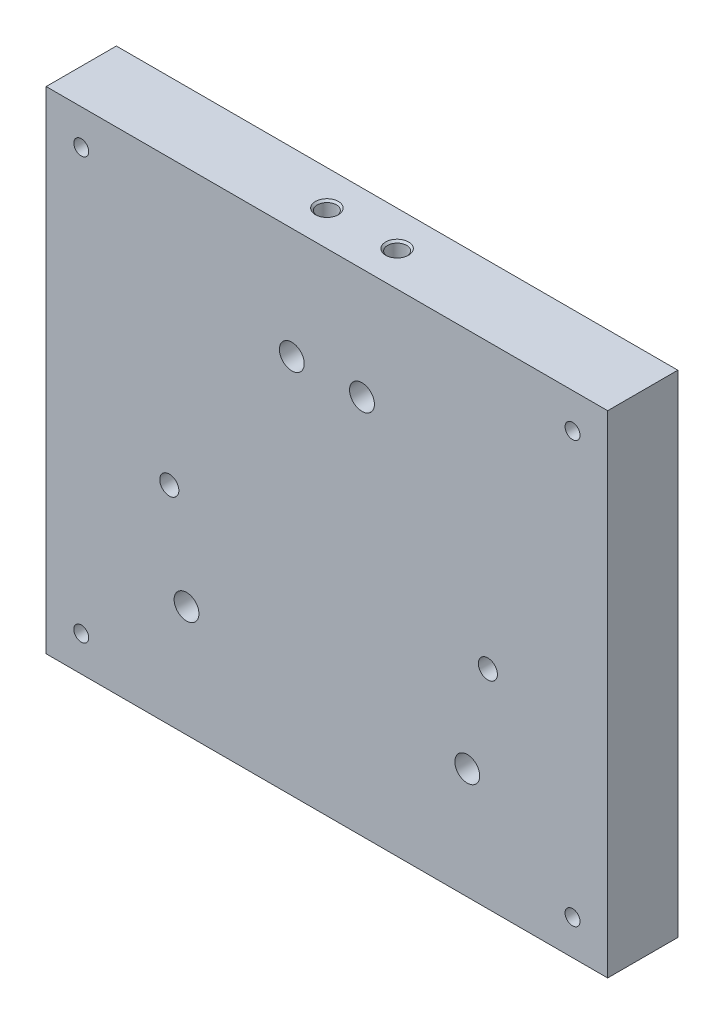
from build123d import *

# Parameters (mm, degrees)
SKETCH1_W                       = 101.6
SKETCH1_H                       = 88.9
BOSS_EXTRUDE1_DEPTH             = 12.7
F_8_32_TAPPED_HOLE1_D           = 3.4544
F_8_32_TAPPED_HOLE1_DEPTH       = 19.05
F_8_32_TAPPED_HOLE1_CSINK_D     = 4.1656
F_8_32_TAPPED_HOLE1_CSINK_ANGLE = 90
F_8_32_TAPPED_HOLE1_TIP         = 1.037806461
F_8_CLEARANCE_HOLE2_D           = 4.4958
F_8_CLEARANCE_HOLE2_DEPTH       = 25.4
F_8_CLEARANCE_HOLE2_TIP         = 1.350674586
F_6_32_TAPPED_HOLE1_D           = 2.7051
F_8_32_TAPPED_HOLE2_D           = 3.4544
F_8_32_TAPPED_HOLE3_D           = 3.4544
F_8_32_TAPPED_HOLE3_DEPTH       = 19.05
F_8_32_TAPPED_HOLE3_TIP         = 1.037806461
F_8_CLEARANCE_HOLE3_D           = 4.4958
F_8_CLEARANCE_HOLE3_DEPTH       = 19.05
F_8_CLEARANCE_HOLE3_TIP         = 1.350674586


with BuildPart() as part:
    # Sketch1 → Boss-Extrude1 (new body)
    with BuildSketch(Plane.XY):
        with Locations((-50.8, 44.45)):
            Rectangle(SKETCH1_W, SKETCH1_H)
    extrude(amount=BOSS_EXTRUDE1_DEPTH)

    # #8-32 Tapped Hole1
    with Locations(Plane(origin=(0, 88.9, 0), x_dir=(1, 0, 0), z_dir=(0, 1, 0))):
        with Locations((-44.45, -6.35), (-57.15, -6.35)):
            CounterSinkHole(F_8_32_TAPPED_HOLE1_D / 2, F_8_32_TAPPED_HOLE1_CSINK_D / 2, depth=F_8_32_TAPPED_HOLE1_DEPTH, counter_sink_angle=F_8_32_TAPPED_HOLE1_CSINK_ANGLE)
            with Locations((0, 0, -(F_8_32_TAPPED_HOLE1_DEPTH + F_8_32_TAPPED_HOLE1_TIP / 2))):  # 118° drill point
                Cone(0, F_8_32_TAPPED_HOLE1_D / 2, F_8_32_TAPPED_HOLE1_TIP, mode=Mode.SUBTRACT)

    # #8 Clearance Hole2
    with Locations(Plane.XY.offset(12.7)):
        with Locations((-44.45, 68.812193539), (-57.15, 68.812193539)):
            Hole(F_8_CLEARANCE_HOLE2_D / 2, depth=F_8_CLEARANCE_HOLE2_DEPTH)
            with Locations((0, 0, -(F_8_CLEARANCE_HOLE2_DEPTH + F_8_CLEARANCE_HOLE2_TIP / 2))):  # 118° drill point
                Cone(0, F_8_CLEARANCE_HOLE2_D / 2, F_8_CLEARANCE_HOLE2_TIP, mode=Mode.SUBTRACT)

    # #6-32 Tapped Hole1 (through all)
    with Locations(Plane.XY.offset(12.7)):
        with Locations((-95.25, 6.35), (-95.25, 82.55), (-6.35, 6.35), (-6.35, 82.55)):
            Hole(F_6_32_TAPPED_HOLE1_D / 2)

    # #8-32 Tapped Hole2 (through all)
    with Locations(Plane(origin=(0, 0, 0), x_dir=(-1, 0, 0), z_dir=(0, 0, -1))):
        with Locations((79.3203, 37.592), (21.675, 37.592)):
            Hole(F_8_32_TAPPED_HOLE2_D / 2)

    # #8-32 Tapped Hole3
    with Locations(Plane(origin=(0, 0, 0), x_dir=(-1, 0, 0), z_dir=(0, -1, 0))):
        with Locations((76.2, -6.35), (25.4, -6.35)):
            Hole(F_8_32_TAPPED_HOLE3_D / 2, depth=F_8_32_TAPPED_HOLE3_DEPTH)
            with Locations((0, 0, -(F_8_32_TAPPED_HOLE3_DEPTH + F_8_32_TAPPED_HOLE3_TIP / 2))):  # 118° drill point
                Cone(0, F_8_32_TAPPED_HOLE3_D / 2, F_8_32_TAPPED_HOLE3_TIP, mode=Mode.SUBTRACT)

    # #8 Clearance Hole3
    with Locations(Plane.XY.offset(12.7)):
        with Locations((-76.2, 20.087806461), (-25.4, 20.087806461)):
            Hole(F_8_CLEARANCE_HOLE3_D / 2, depth=F_8_CLEARANCE_HOLE3_DEPTH)
            with Locations((0, 0, -(F_8_CLEARANCE_HOLE3_DEPTH + F_8_CLEARANCE_HOLE3_TIP / 2))):  # 118° drill point
                Cone(0, F_8_CLEARANCE_HOLE3_D / 2, F_8_CLEARANCE_HOLE3_TIP, mode=Mode.SUBTRACT)


solid = part.part
